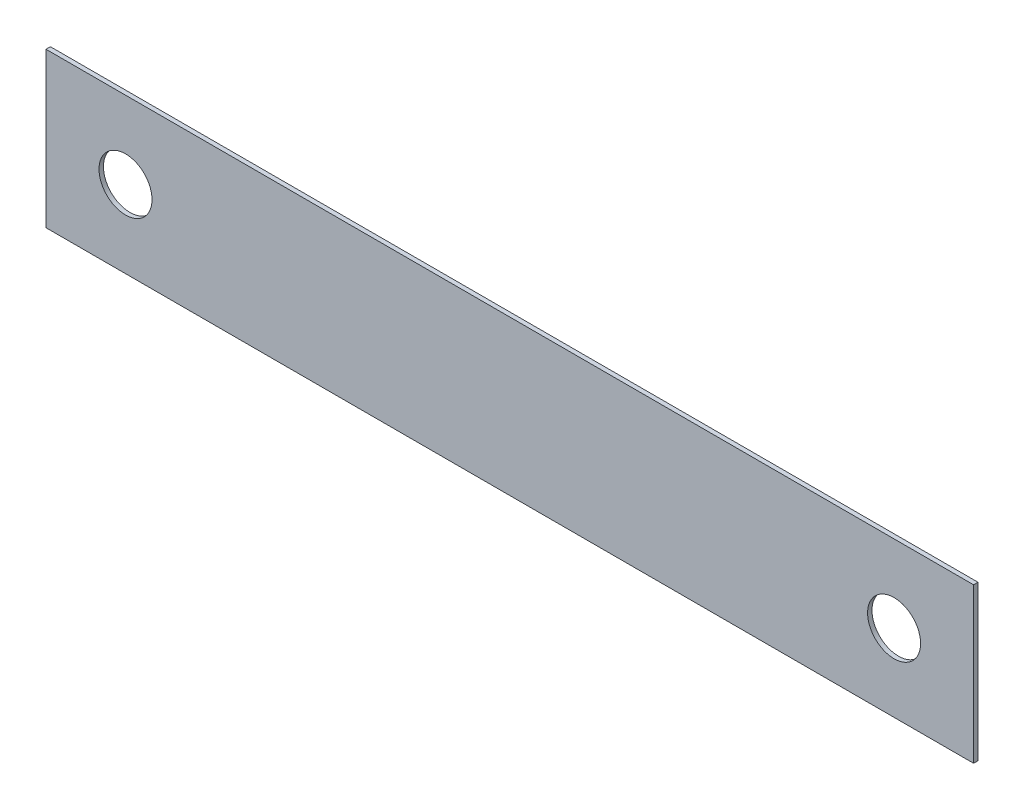
from build123d import *

# Parameters (mm, degrees)
SKETCH1_W           = 105
SKETCH1_H           = 17.5
SKETCH1_R           = 3
BOSS_EXTRUDE1_DEPTH = 0.5


with BuildPart() as part:
    # Sketch1 → Boss-Extrude1 (new body)
    with BuildSketch(Plane.XY):
        with Locations((52.5, 8.75)):
            Rectangle(SKETCH1_W, SKETCH1_H)
        with Locations((9, 8.75)):
            Circle(SKETCH1_R, mode=Mode.SUBTRACT)
        with Locations((96, 8.75)):
            Circle(SKETCH1_R, mode=Mode.SUBTRACT)
    extrude(amount=BOSS_EXTRUDE1_DEPTH)


solid = part.part
